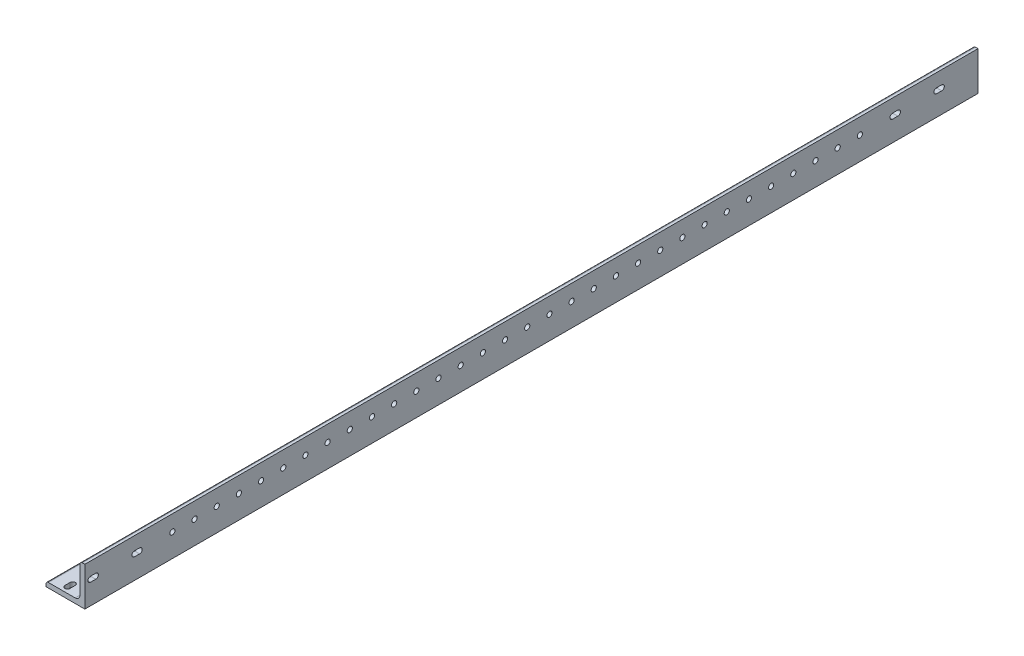
from build123d import *

# Parameters (mm, degrees)
BOSS_EXTRUDE1_DEPTH = 609.6
SKETCH3_W           = 635.2
SKETCH3_H           = 25.4
CUT_EXTRUDE2_DEPTH  = 30.48
SKETCH4_R           = 1.7
CUT_EXTRUDE4_DEPTH  = 611.137198198
SKETCH7_R           = 1.7
CUT_EXTRUDE6_DEPTH  = 611.137198198
CUT_EXTRUDE7_DEPTH  = 611.137198198
CUT_EXTRUDE8_DEPTH  = 611.137198198


with BuildPart() as part:
    # Sketch2 → Boss-Extrude1 (new, symmetric)
    with BuildSketch(Plane.XY):
        with BuildLine():
            Line((-12.7, -12.7), (12.7, -12.7))
            Line((12.7, -12.7), (12.7, 12.7))
            Line((12.7, 12.7), (11.1125, 12.7))
            ThreePointArc((11.1125, 12.7), (9.989967985, 12.235032015), (9.525, 11.1125))
            Line((9.525, 11.1125), (9.525, -6.35))
            ThreePointArc((9.525, -6.35), (8.59506403, -8.59506403), (6.35, -9.525))
            Line((6.35, -9.525), (-11.1125, -9.525))
            ThreePointArc((-11.1125, -9.525), (-12.235032015, -9.989967985), (-12.7, -11.1125))
            Line((-12.7, -11.1125), (-12.7, -12.7))
        make_face()
    extrude(amount=BOSS_EXTRUDE1_DEPTH, both=True)

    # Sketch3 → Cut-Extrude2 (cut)
    with BuildSketch(Plane(origin=(12.7, 0, 0), x_dir=(0, 0, -1), z_dir=(1, 0, 0))):
        with Locations((292, 0)):
            Rectangle(SKETCH3_W, SKETCH3_H)
    extrude(amount=-CUT_EXTRUDE2_DEPTH, mode=Mode.SUBTRACT)

    # Sketch4 → Cut-Extrude4 (cut, through all)
    with BuildSketch(Plane(origin=(0, -9.525, 0), x_dir=(1, 0, 0), z_dir=(0, 1, 0))):
        with Locations(Location((-2.38125, -552.35, 0), (0, 0, 180))):
            Circle(SKETCH4_R)
        with Locations(Location((-2.38125, -537.85, 0), (0, 0, 180))):
            Circle(SKETCH4_R)
        with Locations(Location((-2.38125, -523.35, 0), (0, 0, 180))):
            Circle(SKETCH4_R)
        with Locations(Location((-2.38125, -508.85, 0), (0, 0, 180))):
            Circle(SKETCH4_R)
        with Locations(Location((-2.38125, -494.35, 0), (0, 0, 180))):
            Circle(SKETCH4_R)
        with Locations(Location((-2.38125, -479.85, 0), (0, 0, 180))):
            Circle(SKETCH4_R)
        with Locations(Location((-2.38125, -465.35, 0), (0, 0, 180))):
            Circle(SKETCH4_R)
        with Locations(Location((-2.38125, -450.85, 0), (0, 0, 180))):
            Circle(SKETCH4_R)
        with Locations(Location((-2.38125, -436.35, 0), (0, 0, 180))):
            Circle(SKETCH4_R)
        with Locations(Location((-2.38125, -421.85, 0), (0, 0, 180))):
            Circle(SKETCH4_R)
        with Locations(Location((-2.38125, -407.35, 0), (0, 0, 180))):
            Circle(SKETCH4_R)
        with Locations(Location((-2.38125, -392.85, 0), (0, 0, 180))):
            Circle(SKETCH4_R)
        with Locations(Location((-2.38125, -378.35, 0), (0, 0, 180))):
            Circle(SKETCH4_R)
        with Locations(Location((-2.38125, -363.85, 0), (0, 0, 180))):
            Circle(SKETCH4_R)
        with Locations(Location((-2.38125, -349.35, 0), (0, 0, 180))):
            Circle(SKETCH4_R)
        with Locations(Location((-2.38125, -334.85, 0), (0, 0, 180))):
            Circle(SKETCH4_R)
        with Locations(Location((-2.38125, -320.35, 0), (0, 0, 180))):
            Circle(SKETCH4_R)
        with Locations(Location((-2.38125, -305.85, 0), (0, 0, 180))):
            Circle(SKETCH4_R)
        with Locations(Location((-2.38125, -291.35, 0), (0, 0, 180))):
            Circle(SKETCH4_R)
        with Locations(Location((-2.38125, -276.85, 0), (0, 0, 180))):
            Circle(SKETCH4_R)
        with Locations(Location((-2.38125, -262.35, 0), (0, 0, 180))):
            Circle(SKETCH4_R)
        with Locations(Location((-2.38125, -247.85, 0), (0, 0, 180))):
            Circle(SKETCH4_R)
        with Locations(Location((-2.38125, -233.35, 0), (0, 0, 180))):
            Circle(SKETCH4_R)
        with Locations(Location((-2.38125, -218.85, 0), (0, 0, 180))):
            Circle(SKETCH4_R)
        with Locations(Location((-2.38125, -204.35, 0), (0, 0, 180))):
            Circle(SKETCH4_R)
        with Locations(Location((-2.38125, -189.85, 0), (0, 0, 180))):
            Circle(SKETCH4_R)
        with Locations(Location((-2.38125, -175.35, 0), (0, 0, 180))):
            Circle(SKETCH4_R)
        with Locations(Location((-2.38125, -160.85, 0), (0, 0, 180))):
            Circle(SKETCH4_R)
        with Locations(Location((-2.38125, -146.35, 0), (0, 0, 180))):
            Circle(SKETCH4_R)
        with Locations(Location((-2.38125, -131.85, 0), (0, 0, 180))):
            Circle(SKETCH4_R)
        with Locations(Location((-2.38125, -117.35, 0), (0, 0, 180))):
            Circle(SKETCH4_R)
        with Locations(Location((-2.38125, -102.85, 0), (0, 0, 180))):
            Circle(SKETCH4_R)
    extrude(amount=-CUT_EXTRUDE4_DEPTH, mode=Mode.SUBTRACT)

    # Sketch7 → Cut-Extrude6 (cut, through all)
    with BuildSketch(Plane.ZY.offset(-9.525)):
        with Locations(Location((552.35, 2.38125, 0), (0, 0, 270))):
            Circle(SKETCH7_R)
        with Locations(Location((537.85, 2.38125, 0), (0, 0, 270))):
            Circle(SKETCH7_R)
        with Locations(Location((523.35, 2.38125, 0), (0, 0, 270))):
            Circle(SKETCH7_R)
        with Locations(Location((508.85, 2.38125, 0), (0, 0, 270))):
            Circle(SKETCH7_R)
        with Locations(Location((494.35, 2.38125, 0), (0, 0, 270))):
            Circle(SKETCH7_R)
        with Locations(Location((479.85, 2.38125, 0), (0, 0, 270))):
            Circle(SKETCH7_R)
        with Locations(Location((465.35, 2.38125, 0), (0, 0, 270))):
            Circle(SKETCH7_R)
        with Locations(Location((450.85, 2.38125, 0), (0, 0, 270))):
            Circle(SKETCH7_R)
        with Locations(Location((436.35, 2.38125, 0), (0, 0, 270))):
            Circle(SKETCH7_R)
        with Locations(Location((421.85, 2.38125, 0), (0, 0, 270))):
            Circle(SKETCH7_R)
        with Locations(Location((407.35, 2.38125, 0), (0, 0, 270))):
            Circle(SKETCH7_R)
        with Locations(Location((392.85, 2.38125, 0), (0, 0, 270))):
            Circle(SKETCH7_R)
        with Locations(Location((378.35, 2.38125, 0), (0, 0, 270))):
            Circle(SKETCH7_R)
        with Locations(Location((363.85, 2.38125, 0), (0, 0, 270))):
            Circle(SKETCH7_R)
        with Locations(Location((349.35, 2.38125, 0), (0, 0, 270))):
            Circle(SKETCH7_R)
        with Locations(Location((334.85, 2.38125, 0), (0, 0, 270))):
            Circle(SKETCH7_R)
        with Locations(Location((320.35, 2.38125, 0), (0, 0, 270))):
            Circle(SKETCH7_R)
        with Locations(Location((305.85, 2.38125, 0), (0, 0, 270))):
            Circle(SKETCH7_R)
        with Locations(Location((291.35, 2.38125, 0), (0, 0, 270))):
            Circle(SKETCH7_R)
        with Locations(Location((276.85, 2.38125, 0), (0, 0, 270))):
            Circle(SKETCH7_R)
        with Locations(Location((262.35, 2.38125, 0), (0, 0, 270))):
            Circle(SKETCH7_R)
        with Locations(Location((247.85, 2.38125, 0), (0, 0, 270))):
            Circle(SKETCH7_R)
        with Locations(Location((233.35, 2.38125, 0), (0, 0, 270))):
            Circle(SKETCH7_R)
        with Locations(Location((218.85, 2.38125, 0), (0, 0, 270))):
            Circle(SKETCH7_R)
        with Locations(Location((204.35, 2.38125, 0), (0, 0, 270))):
            Circle(SKETCH7_R)
        with Locations(Location((189.85, 2.38125, 0), (0, 0, 270))):
            Circle(SKETCH7_R)
        with Locations(Location((175.35, 2.38125, 0), (0, 0, 270))):
            Circle(SKETCH7_R)
        with Locations(Location((160.85, 2.38125, 0), (0, 0, 270))):
            Circle(SKETCH7_R)
        with Locations(Location((146.35, 2.38125, 0), (0, 0, 270))):
            Circle(SKETCH7_R)
        with Locations(Location((131.85, 2.38125, 0), (0, 0, 270))):
            Circle(SKETCH7_R)
        with Locations(Location((117.35, 2.38125, 0), (0, 0, 270))):
            Circle(SKETCH7_R)
        with Locations(Location((102.85, 2.38125, 0), (0, 0, 270))):
            Circle(SKETCH7_R)
    extrude(amount=-CUT_EXTRUDE6_DEPTH, mode=Mode.SUBTRACT)

    # Sketch8 → Cut-Extrude7 (cut, through all)
    with BuildSketch(Plane.ZY.offset(-9.525)):
        with BuildLine():
            Line((49.3305, 4.0825), (52.7305, 4.0825))
            ThreePointArc((52.7305, 4.0825), (54.4305, 2.3825), (52.7305, 0.6825))
            Line((52.7305, 0.6825), (49.3305, 0.6825))
            ThreePointArc((49.3305, 0.6825), (47.6305, 2.3825), (49.3305, 4.0825))
        make_face()
        with BuildLine():
            Line((78.0325, 4.0825), (81.4325, 4.0825))
            ThreePointArc((81.4325, 4.0825), (83.1325, 2.3825), (81.4325, 0.6825))
            Line((81.4325, 0.6825), (78.0325, 0.6825))
            ThreePointArc((78.0325, 0.6825), (76.3325, 2.3825), (78.0325, 4.0825))
        make_face()
        with BuildLine():
            Line((573.7675, 4.0825), (577.1675, 4.0825))
            ThreePointArc((577.1675, 4.0825), (578.8675, 2.3825), (577.1675, 0.6825))
            Line((577.1675, 0.6825), (573.7675, 0.6825))
            ThreePointArc((573.7675, 0.6825), (572.0675, 2.3825), (573.7675, 4.0825))
        make_face()
        with BuildLine():
            Line((602.4695, 4.0825), (605.8695, 4.0825))
            ThreePointArc((605.8695, 4.0825), (607.5695, 2.3825), (605.8695, 0.6825))
            Line((605.8695, 0.6825), (602.4695, 0.6825))
            ThreePointArc((602.4695, 0.6825), (600.7695, 2.3825), (602.4695, 4.0825))
        make_face()
    extrude(amount=-CUT_EXTRUDE7_DEPTH, mode=Mode.SUBTRACT)

    # Sketch9 → Cut-Extrude8 (cut, through all)
    with BuildSketch(Plane(origin=(0, -9.525, 0), x_dir=(1, 0, 0), z_dir=(0, 1, 0))):
        with BuildLine():
            Line((-4.0825, -605.8695), (-4.0825, -602.4695))
            ThreePointArc((-4.0825, -602.4695), (-2.3825, -600.7695), (-0.6825, -602.4695))
            Line((-0.6825, -602.4695), (-0.6825, -605.8695))
            ThreePointArc((-0.6825, -605.8695), (-2.3825, -607.5695), (-4.0825, -605.8695))
        make_face()
        with BuildLine():
            Line((-4.0825, -577.1675), (-4.0825, -573.7675))
            ThreePointArc((-4.0825, -573.7675), (-2.3825, -572.0675), (-0.6825, -573.7675))
            Line((-0.6825, -573.7675), (-0.6825, -577.1675))
            ThreePointArc((-0.6825, -577.1675), (-2.3825, -578.8675), (-4.0825, -577.1675))
        make_face()
        with BuildLine():
            Line((-4.0825, -81.4325), (-4.0825, -78.0325))
            ThreePointArc((-4.0825, -78.0325), (-2.3825, -76.3325), (-0.6825, -78.0325))
            Line((-0.6825, -78.0325), (-0.6825, -81.4325))
            ThreePointArc((-0.6825, -81.4325), (-2.3825, -83.1325), (-4.0825, -81.4325))
        make_face()
        with BuildLine():
            Line((-4.0825, -52.7305), (-4.0825, -49.3305))
            ThreePointArc((-4.0825, -49.3305), (-2.3825, -47.6305), (-0.6825, -49.3305))
            Line((-0.6825, -49.3305), (-0.6825, -52.7305))
            ThreePointArc((-0.6825, -52.7305), (-2.3825, -54.4305), (-4.0825, -52.7305))
        make_face()
    extrude(amount=-CUT_EXTRUDE8_DEPTH, mode=Mode.SUBTRACT)


solid = part.part
